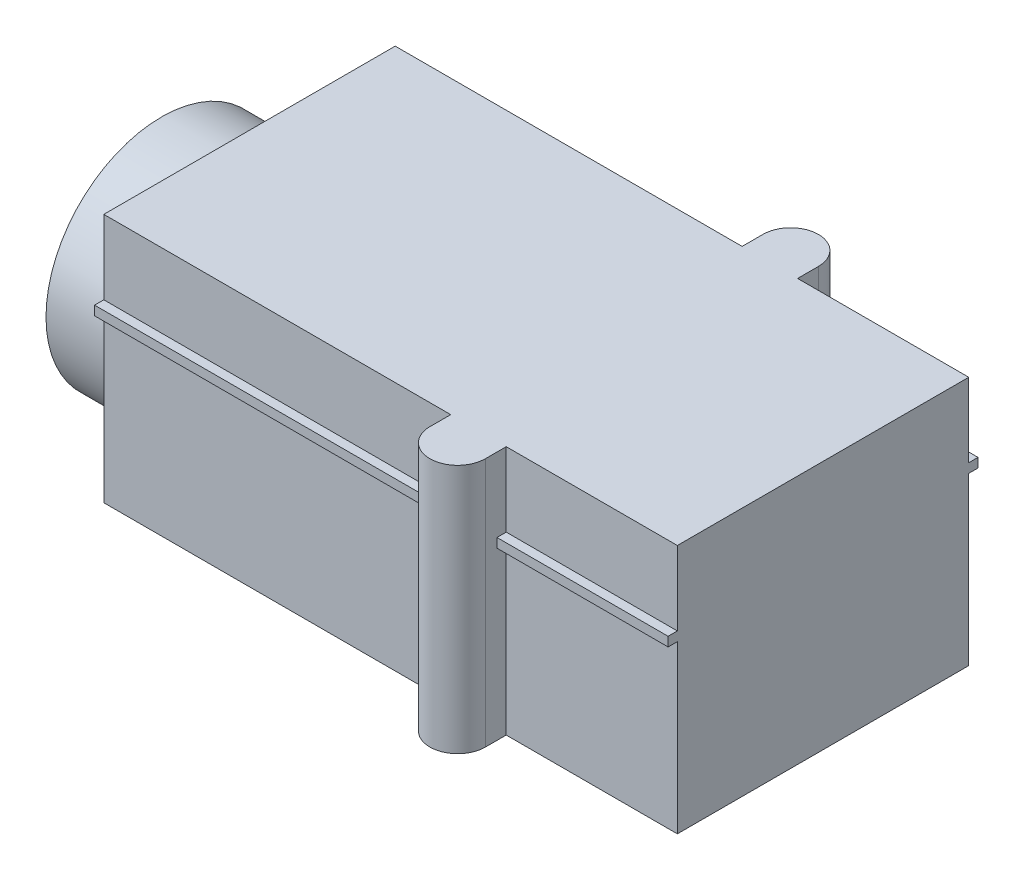
from build123d import *

# Parameters (mm, degrees)
BOSS_EXTRUDE1_DEPTH = 5.4
SKETCH2_R           = 2.5
BOSS_EXTRUDE2_DEPTH = 1.9
SKETCH3_W           = 12.4
SKETCH3_H           = 6.7
BOSS_EXTRUDE3_DEPTH = 0.2


with BuildPart() as part:
    # Sketch1 → Boss-Extrude1 (new body)
    with BuildSketch(Plane(origin=(0, 0, 0), x_dir=(1, 0, 0), z_dir=(0, 1, 0))):
        with BuildLine():
            Line((0, -3.15), (0, 3.15))
            Line((0, 3.15), (7.5, 3.15))
            Line((7.5, 3.15), (7.5, 3.6))
            ThreePointArc((7.5, 3.6), (8.1, 4.2), (8.7, 3.6))
            Line((8.7, 3.6), (8.7, 3.15))
            Line((8.7, 3.15), (12.4, 3.15))
            Line((12.4, 3.15), (12.4, -3.15))
            Line((12.4, -3.15), (8.7, -3.15))
            Line((8.7, -3.15), (8.7, -3.6))
            ThreePointArc((8.7, -3.6), (8.1, -4.2), (7.5, -3.6))
            Line((7.5, -3.6), (7.5, -3.15))
            Line((7.5, -3.15), (0, -3.15))
        make_face()
    extrude(amount=BOSS_EXTRUDE1_DEPTH)

    # Sketch2 → Boss-Extrude2 (add)
    with BuildSketch(Plane.ZY):
        with Locations(Location((0, 2.2, 0), (0, 0, 241.642363424))):  # turned: the seam where the file's is
            Circle(SKETCH2_R)
    extrude(amount=BOSS_EXTRUDE2_DEPTH)

    # Sketch3 → Boss-Extrude3 (add)
    with BuildSketch(Plane(origin=(0, 3.6, 0), x_dir=(-1, 0, 0), z_dir=(0, -1, 0))):
        with Locations((-6.2, 0)):
            Rectangle(SKETCH3_W, SKETCH3_H)
    extrude(amount=-BOSS_EXTRUDE3_DEPTH)


solid = part.part
